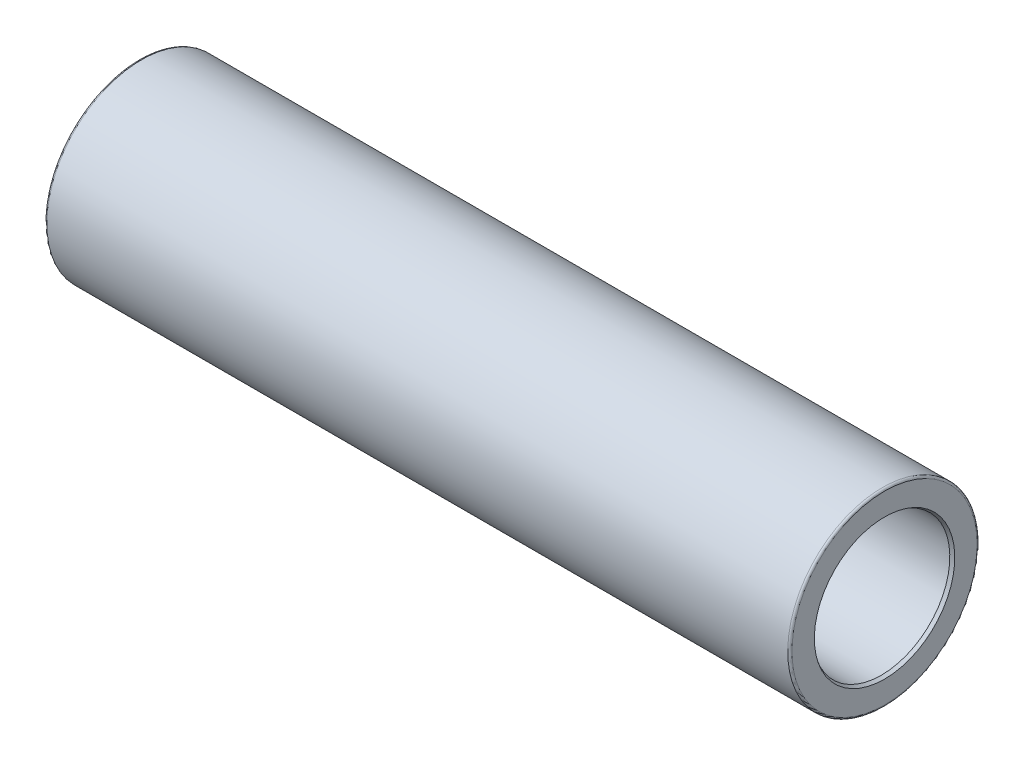
from build123d import *


with BuildPart() as part:
    # Sketch1 → Base-Revolve (revolve)
    with BuildSketch(Plane.XY):
        with BuildLine():
            Line((-177, 32.5), (-177, 44))
            ThreePointArc((-177, 44), (-176.707106781, 44.707106781), (-176, 45))
            Line((-176, 45), (176, 45))
            ThreePointArc((176, 45), (176.707106781, 44.707106781), (177, 44))
            Line((177, 44), (177, 32.5))
            Line((177, 32.5), (120.462610506, 32.5))
            Line((120.462610506, 32.5), (118.5, 33.5))
            Line((118.5, 33.5), (116.5, 33.5))
            Line((116.5, 33.5), (116.5, 31.5))
            Line((116.5, 31.5), (107.176326981, 31.5))
            ThreePointArc((107.176326981, 31.5), (107.002678803, 31.515192247), (106.834306837, 31.560307379))
            Line((106.834306837, 31.560307379), (100.296999614, 33.939692621))
            ThreePointArc((100.296999614, 33.939692621), (100.128627648, 33.984807753), (99.954979471, 34))
            Line((99.954979471, 34), (-99.954979471, 34))
            ThreePointArc((-99.954979471, 34), (-100.128627648, 33.984807753), (-100.296999614, 33.939692621))
            Line((-100.296999614, 33.939692621), (-106.834306837, 31.560307379))
            ThreePointArc((-106.834306837, 31.560307379), (-107.002678803, 31.515192247), (-107.176326981, 31.5))
            Line((-107.176326981, 31.5), (-116.5, 31.5))
            Line((-116.5, 31.5), (-116.5, 33.5))
            Line((-116.5, 33.5), (-118.5, 33.5))
            Line((-118.5, 33.5), (-120.462610506, 32.5))
            Line((-120.462610506, 32.5), (-177, 32.5))
        make_face()
    revolve(axis=Axis((-177, 0, 0), (1, 0, 0)))

    # Sketch5 → 2.5 x 30 gr reifning (revolve, cut)
    with BuildSketch(Plane.XY):
        Polygon((177, 32.5), (177, 33.366025404), (175.5, 32.5), align=None)
        Polygon((-175.5, 32.5), (-177, 33.366025404), (-177, 32.5), align=None)
    revolve(axis=Axis((0, 0, 0), (1, 0, 0)), mode=Mode.SUBTRACT)


solid = part.part
